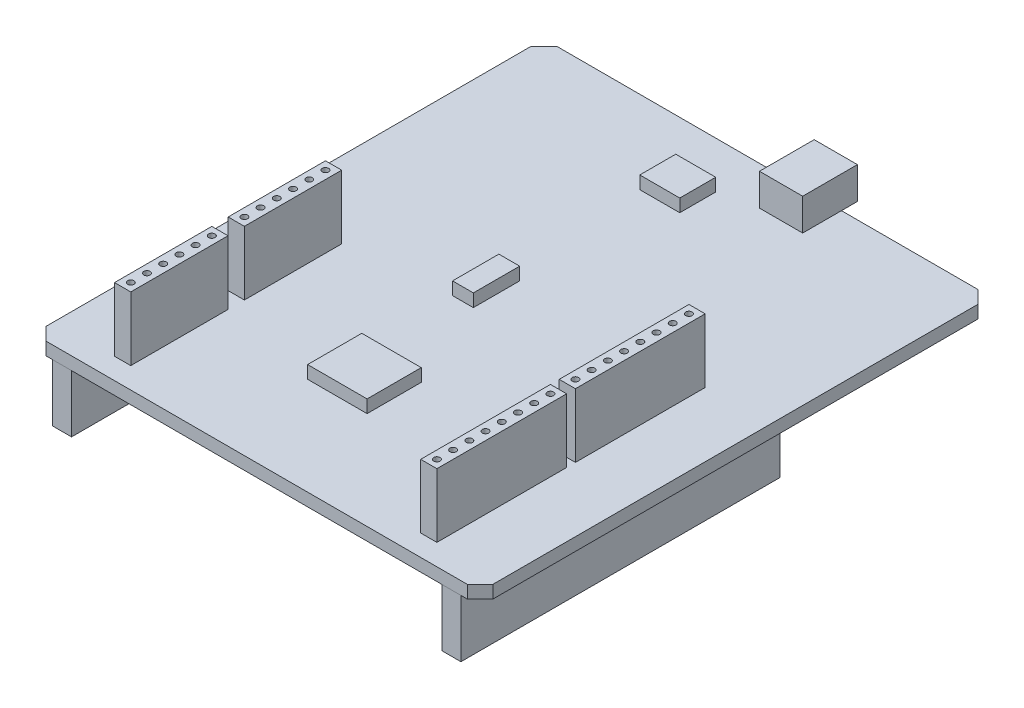
from build123d import *

# Parameters (mm, degrees)
SKETCH1_W             = 70
SKETCH1_H             = 80
BOSS_EXTRUDE1_DEPTH   = 2
SKETCH3_W             = 3
SKETCH3_H             = 9
BOSS_EXTRUDE4_DEPTH   = 50
BOSS_EXTRUDE4_2_DEPTH = 50
SKETCH2_W             = 2.54
SKETCH2_H             = 15.24
SKETCH2_R             = 0.5
SKETCH2_H_2           = 20.32
BOSS_EXTRUDE5_DEPTH   = 10
SKETCH4_W             = 6.772712715
SKETCH4_H             = 8.573417308
BOSS_EXTRUDE6_DEPTH   = 5
SKETCH5_W             = 9.316082399
SKETCH5_H             = 8.485562272
SKETCH5_W_2           = 3.258498045
SKETCH5_H_2           = 7.258320338
SKETCH5_W_3           = 6.258978231
SKETCH5_H_3           = 5.634617383
BOSS_EXTRUDE7_DEPTH   = 2
CHAMFER1_SIZE         = 2


with BuildPart() as part:
    # Sketch1 → Boss-Extrude1 (new body)
    with BuildSketch(Plane(origin=(0, 0, 0), x_dir=(1, 0, 0), z_dir=(0, 1, 0))):
        with Locations((-41.191481692, 62.486230982)):
            Rectangle(SKETCH1_W, SKETCH1_H)
    extrude(amount=BOSS_EXTRUDE1_DEPTH)

    # Sketch2 → Boss-Extrude5 (add)
    with BuildSketch(Plane(origin=(0, 2, 0), x_dir=(1, 0, 0), z_dir=(0, 1, 0))):
        with Locations((-65.495211753, 51.217634077)):
            Rectangle(SKETCH2_W, SKETCH2_H)
        with Locations((-65.495211753, 57.567634077)):
            Circle(SKETCH2_R, mode=Mode.SUBTRACT)
        with Locations((-65.495211753, 55.027634077)):
            Circle(SKETCH2_R, mode=Mode.SUBTRACT)
        with Locations((-65.495211753, 52.487634077)):
            Circle(SKETCH2_R, mode=Mode.SUBTRACT)
        with Locations((-65.495211753, 49.947634077)):
            Circle(SKETCH2_R, mode=Mode.SUBTRACT)
        with Locations((-65.495211753, 47.407634077)):
            Circle(SKETCH2_R, mode=Mode.SUBTRACT)
        with Locations((-65.495211753, 44.867634077)):
            Circle(SKETCH2_R, mode=Mode.SUBTRACT)
        with Locations((-65.495211753, 33.417634117)):
            Rectangle(SKETCH2_W, SKETCH2_H)
        with Locations((-65.495211753, 39.767634117)):
            Circle(SKETCH2_R, mode=Mode.SUBTRACT)
        with Locations((-65.495211753, 37.227634117)):
            Circle(SKETCH2_R, mode=Mode.SUBTRACT)
        with Locations((-65.495211753, 34.687634117)):
            Circle(SKETCH2_R, mode=Mode.SUBTRACT)
        with Locations((-65.495211753, 32.147634117)):
            Circle(SKETCH2_R, mode=Mode.SUBTRACT)
        with Locations((-65.495211753, 29.607634117)):
            Circle(SKETCH2_R, mode=Mode.SUBTRACT)
        with Locations((-65.495211753, 27.067634117)):
            Circle(SKETCH2_R, mode=Mode.SUBTRACT)
        with Locations((-17.535211153, 57.657633897)):
            Rectangle(SKETCH2_W, SKETCH2_H_2)
        with Locations((-17.535211153, 66.547633897)):
            Circle(SKETCH2_R, mode=Mode.SUBTRACT)
        with Locations((-17.535211153, 64.007633897)):
            Circle(SKETCH2_R, mode=Mode.SUBTRACT)
        with Locations((-17.535211153, 61.467633897)):
            Circle(SKETCH2_R, mode=Mode.SUBTRACT)
        with Locations((-17.535211153, 58.927633897)):
            Circle(SKETCH2_R, mode=Mode.SUBTRACT)
        with Locations((-17.535211153, 56.387633897)):
            Circle(SKETCH2_R, mode=Mode.SUBTRACT)
        with Locations((-17.535211153, 53.847633897)):
            Circle(SKETCH2_R, mode=Mode.SUBTRACT)
        with Locations((-17.535211153, 51.307633897)):
            Circle(SKETCH2_R, mode=Mode.SUBTRACT)
        with Locations((-17.535211153, 48.767633897)):
            Circle(SKETCH2_R, mode=Mode.SUBTRACT)
        with Locations((-17.535211153, 35.957634117)):
            Rectangle(SKETCH2_W, SKETCH2_H_2)
        with Locations((-17.535211153, 44.847634117)):
            Circle(SKETCH2_R, mode=Mode.SUBTRACT)
        with Locations((-17.535211153, 42.307634117)):
            Circle(SKETCH2_R, mode=Mode.SUBTRACT)
        with Locations((-17.535211153, 39.767634117)):
            Circle(SKETCH2_R, mode=Mode.SUBTRACT)
        with Locations((-17.535211153, 37.227634117)):
            Circle(SKETCH2_R, mode=Mode.SUBTRACT)
        with Locations((-17.535211153, 34.687634117)):
            Circle(SKETCH2_R, mode=Mode.SUBTRACT)
        with Locations((-17.535211153, 32.147634117)):
            Circle(SKETCH2_R, mode=Mode.SUBTRACT)
        with Locations((-17.535211153, 29.607634117)):
            Circle(SKETCH2_R, mode=Mode.SUBTRACT)
        with Locations((-17.535211153, 27.067634117)):
            Circle(SKETCH2_R, mode=Mode.SUBTRACT)
    extrude(amount=BOSS_EXTRUDE5_DEPTH)

    # Sketch4 → Boss-Extrude6 (add)
    with BuildSketch(Plane(origin=(0, 2, 0), x_dir=(1, 0, 0), z_dir=(0, 1, 0))):
        with Locations((-32.966811874, 100.698060504)):
            Rectangle(SKETCH4_W, SKETCH4_H)
    extrude(amount=BOSS_EXTRUDE6_DEPTH)

    # Sketch5 → Boss-Extrude7 (add)
    with BuildSketch(Plane(origin=(0, 2, 0), x_dir=(1, 0, 0), z_dir=(0, 1, 0))):
        with Locations((-43.859732146, 42.037559089)):
            Rectangle(SKETCH5_W, SKETCH5_H)
        with Locations((-46.888524323, 64.127636927)):
            Rectangle(SKETCH5_W_2, SKETCH5_H_2)
        with Locations((-45.093709827, 92.355441802)):
            Rectangle(SKETCH5_W_3, SKETCH5_H_3)
    extrude(amount=BOSS_EXTRUDE7_DEPTH)

    # Chamfer1
    chamfer1_edges = [part.edges().sort_by_distance(p)[0] for p in [
        (-76.191481692, 1, -102.486230982),
        (-6.191481692, 1, -102.486230982),
        (-6.191481692, 1, -22.486230982),
        (-76.191481692, 1, -22.486230982),
    ]]
    chamfer(chamfer1_edges, length=CHAMFER1_SIZE)


with BuildPart() as body_2:
    # Sketch3 → Boss-Extrude4 (new body)
    with BuildSketch(Plane.XY.offset(-22.486230982)):
        with Locations((-71.691481692, -4.5)):
            Rectangle(SKETCH3_W, SKETCH3_H)
    extrude(amount=-BOSS_EXTRUDE4_DEPTH)


with BuildPart() as body_3:
    # Sketch3 → Boss-Extrude4 2 (new body)
    with BuildSketch(Plane.XY.offset(-22.486230982)):
        with Locations((-10.691481692, -4.5)):
            Rectangle(SKETCH3_W, SKETCH3_H)
    extrude(amount=-BOSS_EXTRUDE4_2_DEPTH)


solid = Compound([part.part, body_2.part, body_3.part])
